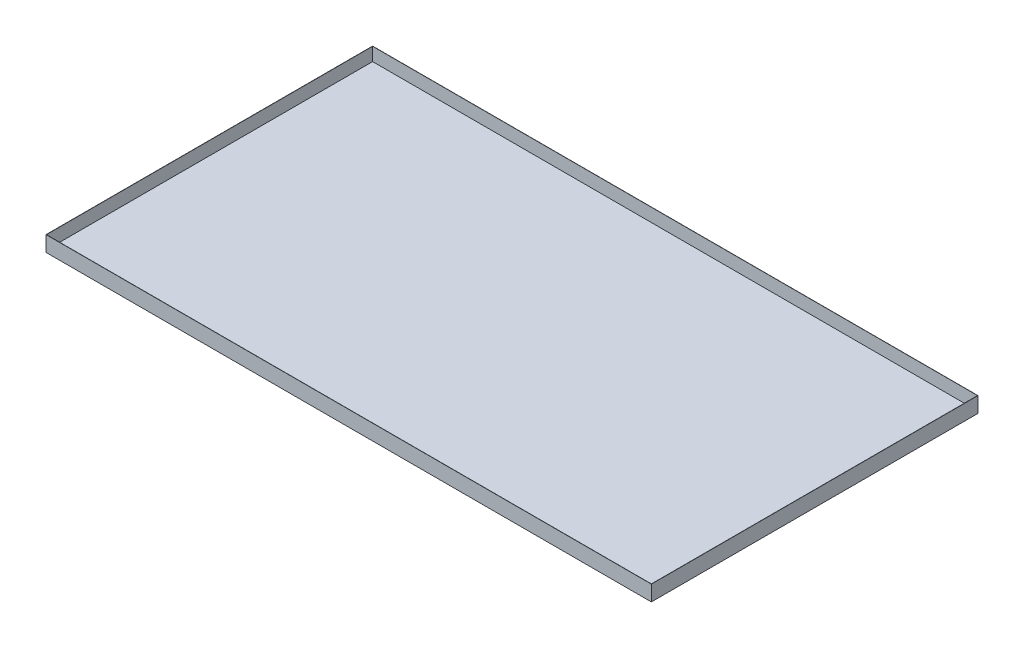
from build123d import *

# Parameters (mm, degrees)
SKETCH_1_W      = 27820
SKETCH_1_H      = 15000
EXTRUDE_1_DEPTH = 100
SKETCH_3_W      = 15000
SKETCH_3_H      = 710
EXTRUDE_2_DEPTH = 10
SKETCH_4_W      = 27830
SKETCH_4_H      = 710
EXTRUDE_3_DEPTH = 10
SKETCH_5_W      = 15010
SKETCH_5_H      = 710
EXTRUDE_4_DEPTH = 10
SKETCH_7_W      = 27840
SKETCH_7_H      = 710
EXTRUDE_6_DEPTH = 10


with BuildPart() as part:
    # 草图1 → 凸台-拉伸1 (new body)
    with BuildSketch(Plane(origin=(0, 0, 0), x_dir=(1, 0, 0), z_dir=(0, 1, 0))):
        Rectangle(SKETCH_1_W, SKETCH_1_H)
    extrude(amount=EXTRUDE_1_DEPTH)

    # 草图3 → 凸台-拉伸2 (add)
    with BuildSketch(Plane.ZY.offset(13910)):
        with Locations((0, 355)):
            Rectangle(SKETCH_3_W, SKETCH_3_H)
    extrude(amount=EXTRUDE_2_DEPTH)

    # 草图4 → 凸台-拉伸3 (add)
    with BuildSketch(Plane.XY.offset(7500)):
        with Locations((-5, 355)):
            Rectangle(SKETCH_4_W, SKETCH_4_H)
    extrude(amount=EXTRUDE_3_DEPTH)

    # 草图5 → 凸台-拉伸4 (add)
    with BuildSketch(Plane(origin=(13910, 0, 0), x_dir=(0, 0, -1), z_dir=(1, 0, 0))):
        with Locations((-5, 355)):
            Rectangle(SKETCH_5_W, SKETCH_5_H)
    extrude(amount=EXTRUDE_4_DEPTH)

    # 草图7 → 凸台-拉伸6 (add)
    with BuildSketch(Plane(origin=(0, 0, -7500), x_dir=(-1, 0, 0), z_dir=(0, 0, -1))):
        with Locations((0, 355)):
            Rectangle(SKETCH_7_W, SKETCH_7_H)
    extrude(amount=EXTRUDE_6_DEPTH)


solid = part.part
